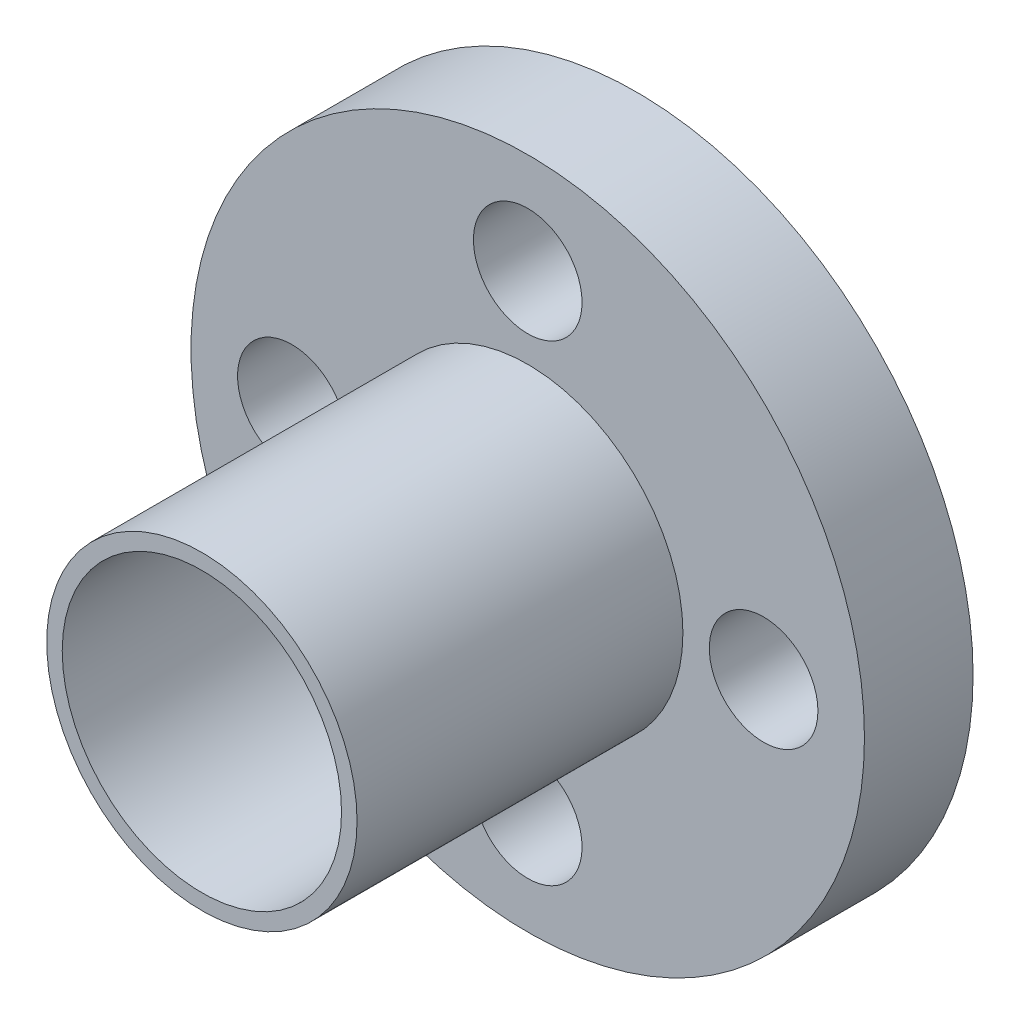
from build123d import *

# Parameters (mm, degrees)
SKETCH1_R           = 5
SKETCH1_R_2         = 4.5
BOSS_EXTRUDE1_DEPTH = 15
SKETCH2_R           = 10.85
BOSS_EXTRUDE2_DEPTH = 3.5
SKETCH4_R           = 1.75
CUT_EXTRUDE1_DEPTH  = 15.5
SKETCH5_R           = 4.5
CUT_EXTRUDE2_DEPTH  = 15.5


with BuildPart() as part:
    # Sketch1 → Boss-Extrude1 (new body)
    with BuildSketch(Plane.XY):
        Circle(SKETCH1_R)
        Circle(SKETCH1_R_2, mode=Mode.SUBTRACT)
    extrude(amount=BOSS_EXTRUDE1_DEPTH)

    # Sketch2 → Boss-Extrude2 (add)
    with BuildSketch(Plane.XY.offset(4.5)):
        Circle(SKETCH2_R)
    extrude(amount=-BOSS_EXTRUDE2_DEPTH)

    # Sketch4 → Cut-Extrude1 (cut)
    with BuildSketch(Plane.XY.offset(4.5)):
        with Locations((0, 7.6)):
            Circle(SKETCH4_R)
        with Locations((7.6, 0)):
            Circle(SKETCH4_R)
        with Locations((0, -7.6)):
            Circle(SKETCH4_R)
        with Locations((-7.6, 0)):
            Circle(SKETCH4_R)
    extrude(amount=-CUT_EXTRUDE1_DEPTH, mode=Mode.SUBTRACT)

    # Sketch5 → Cut-Extrude2 (cut)
    with BuildSketch(Plane(origin=(0, 0, 1), x_dir=(-1, 0, 0), z_dir=(0, 0, -1))):
        with Locations(Location((0, 0, 0), (0, 0, 180))):
            Circle(SKETCH5_R)
    extrude(amount=-CUT_EXTRUDE2_DEPTH, mode=Mode.SUBTRACT)


solid = part.part
